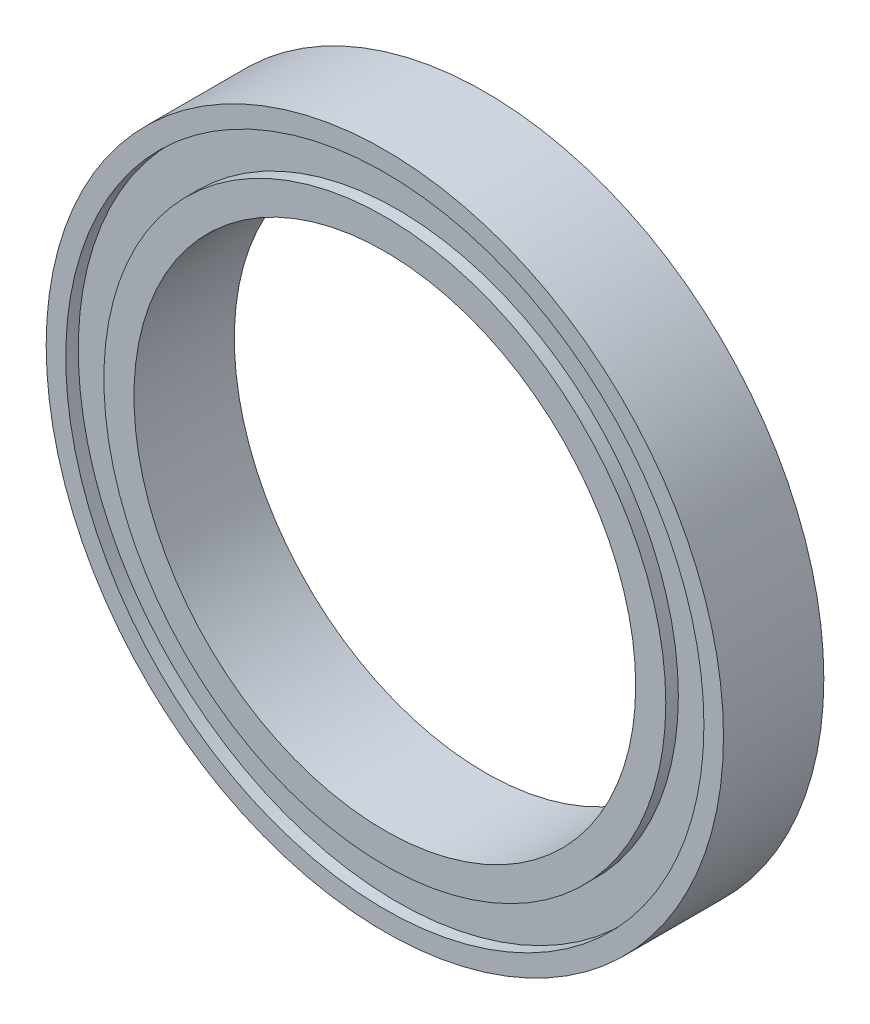
from build123d import *

# Parameters (mm, degrees)
SKETCH_1_R          = 13.5
SKETCH_1_R_2        = 10
EXTRUDE_1_DEPTH     = 4
SKETCH_2_R          = 12.72
SKETCH_2_R_2        = 11.2
CUT_EXTRUDE_1_DEPTH = 0.5
SKETCH_3_R          = 12.72
SKETCH_3_R_2        = 11.2
CUT_EXTRUDE_2_DEPTH = 0.5


with BuildPart() as part:
    # 草圖1 → 填料-伸長1 (new body)
    with BuildSketch(Plane.XY):
        Circle(SKETCH_1_R)
        Circle(SKETCH_1_R_2, mode=Mode.SUBTRACT)
    extrude(amount=EXTRUDE_1_DEPTH)

    # 草圖2 → 除料-伸長1 (cut)
    with BuildSketch(Plane.XY.offset(4)):
        Circle(SKETCH_2_R)
        Circle(SKETCH_2_R_2, mode=Mode.SUBTRACT)
    extrude(amount=-CUT_EXTRUDE_1_DEPTH, mode=Mode.SUBTRACT)

    # 草圖3 → 除料-伸長2 (cut)
    with BuildSketch(Plane(origin=(0, 0, 0), x_dir=(-1, 0, 0), z_dir=(0, 0, -1))):
        Circle(SKETCH_3_R)
        Circle(SKETCH_3_R_2, mode=Mode.SUBTRACT)
    extrude(amount=-CUT_EXTRUDE_2_DEPTH, mode=Mode.SUBTRACT)


solid = part.part
